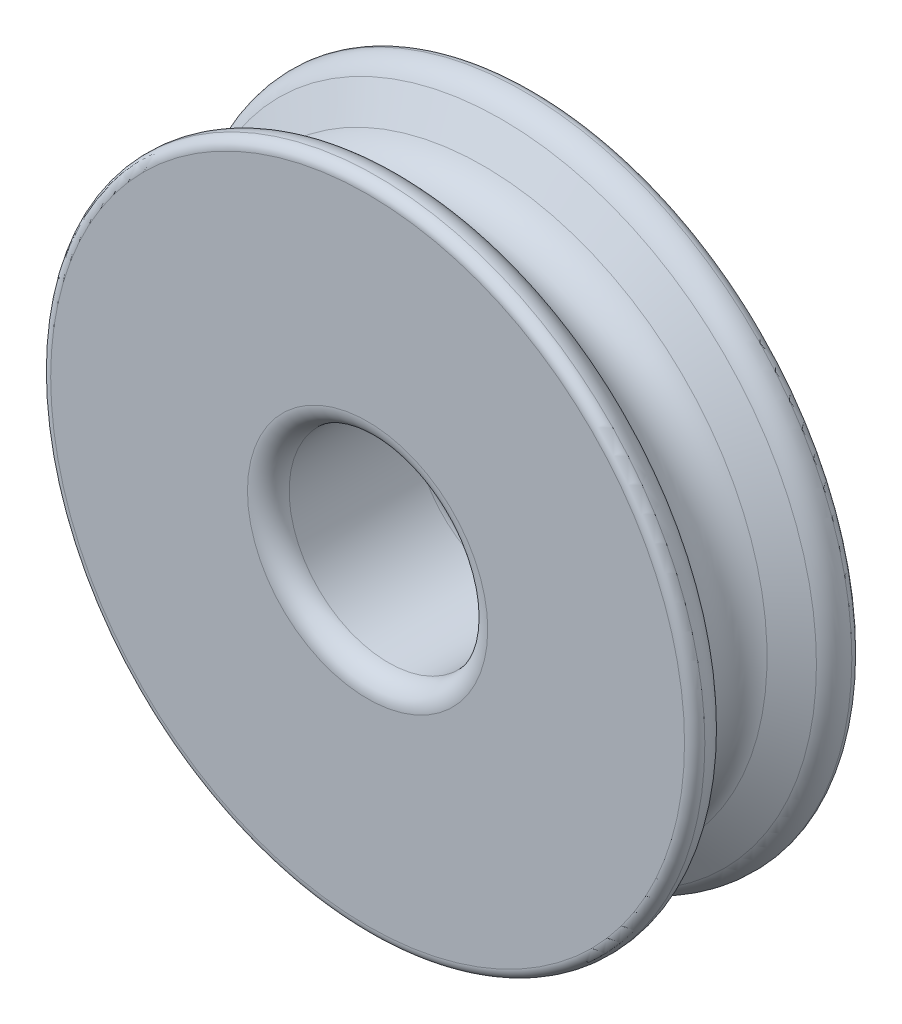
from build123d import *

# Parameters (mm, degrees)
SKETCH2_R          = 4.7625
CUT_EXTRUDE2_DEPTH = 9
FILLET3_R          = 1


with BuildPart() as part:
    # Sketch1 → Revolve1 (revolve)
    with BuildSketch(Plane(origin=(0, 0, 0), x_dir=(0, 0, -1), z_dir=(1, 0, 0))):
        with BuildLine():
            Line((4, 0), (-4, 0))
            Line((-4, 0), (-4, 15.200626476))
            ThreePointArc((-4, 15.200626476), (-3.86229189, 15.54521984), (-3.525021653, 15.7))
            ThreePointArc((-3.525021653, 15.7), (-2.891169071, 15.555426146), (-2.425739201, 15.101503541))
            Line((-2.425739201, 15.101503541), (-1.558845727, 13.6))
            ThreePointArc((-1.558845727, 13.6), (0, 12.7), (1.558845727, 13.6))
            Line((1.558845727, 13.6), (2.425739201, 15.101503541))
            ThreePointArc((2.425739201, 15.101503541), (2.891169071, 15.555426146), (3.525021653, 15.7))
            ThreePointArc((3.525021653, 15.7), (3.86229189, 15.54521984), (4, 15.200626476))
            Line((4, 15.200626476), (4, 0))
        make_face()
    revolve(axis=Axis((0, 0, -4), (0, 0, 1)))

    # Sketch2 → Cut-Extrude2 (cut, through all)
    with BuildSketch(Plane.XY.offset(4)):
        Circle(SKETCH2_R)
    extrude(amount=-CUT_EXTRUDE2_DEPTH, mode=Mode.SUBTRACT)

    # Fillet3
    fillet3_edges = [part.edges().sort_by_distance(p)[0] for p in [
        (-4.7625, 0, -4),
        (-4.7625, 0, 4),
    ]]
    fillet(fillet3_edges, radius=FILLET3_R)


solid = part.part
